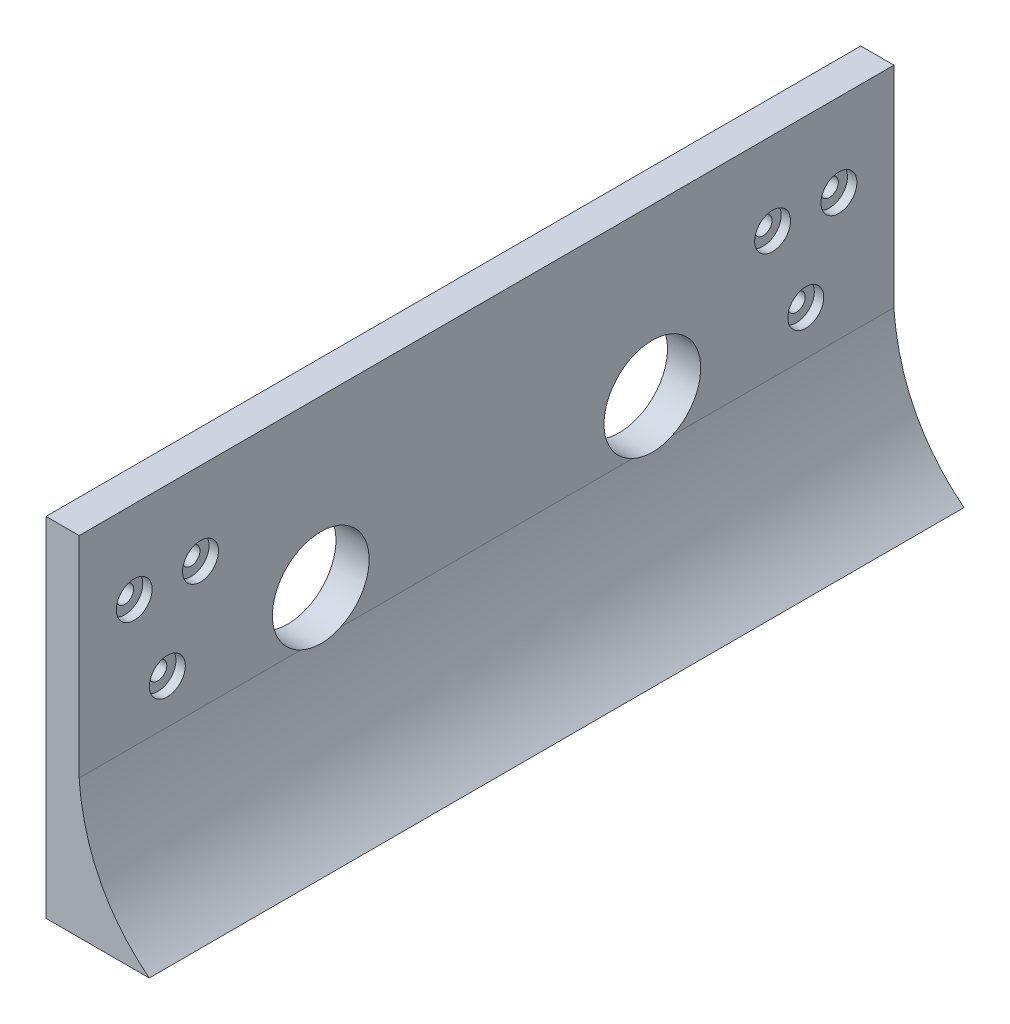
from build123d import *

# Parameters (mm, degrees)
SALIENTE_EXTRUIR1_DEPTH           = 73.717911
CORTAR_EXTRUIR1_REACH             = 8
CROQUIS3_R                        = 8.75
CORTAR_EXTRUIR1_DIRECTION_2_DEPTH = 0.4
CORTAR_EXTRUIR2_REACH             = 8
CROQUIS4_R                        = 1.6
CORTAR_EXTRUIR2_DIRECTION_2_DEPTH = 0.4
CROQUIS5_R                        = 3.25
CORTAR_EXTRUIR3_DEPTH             = 2.5


with BuildPart() as part:
    # Croquis1 → Saliente-Extruir1 (new body)
    with BuildSketch(Plane.XY):
        with BuildLine():
            Line((86.324875029, 72), (86.324875029, 9))
            Line((86.324875029, 9), (105, 9))
            add(Edge.make_bspline(
                [(105, 9), (93.439731725, 18.227197661), (92.324875029, 34)],
                knots=[0, 0, 0, 1, 1, 1], degree=2))
            Line((92.324875029, 34), (92.324875029, 72))
            Line((92.324875029, 72), (86.324875029, 72))
        make_face()
    saliente_extruir1 = extrude(amount=-SALIENTE_EXTRUIR1_DEPTH)

    # Simetr_a1: Saliente-Extruir1 across Front Plane
    add(saliente_extruir1.mirror(Plane.XY))

    # Croquis3 → Cortar-Extruir1 (cut, up to next)
    with BuildSketch(Plane(origin=(92.324875029, 0, 0), x_dir=(0, 0, -1), z_dir=(1, 0, 0)), mode=Mode.PRIVATE) as cortar_extruir1_sk1:
        with BuildLine():
            Line((33.54436172, 34), (26.45563828, 34))
            ThreePointArc((26.45563828, 34), (30, 33.25), (33.54436172, 34))
        make_face()
    cortar_extruir1_tool1 = extrude(cortar_extruir1_sk1.sketch, amount=-CORTAR_EXTRUIR1_REACH, mode=Mode.PRIVATE) & part.part
    add(cortar_extruir1_tool1.solids().sort_by_distance((92.324875, 33.69887, -30))[0], mode=Mode.SUBTRACT)
    # Croquis3 → Cortar-Extruir1 (cut, up to next)
    with BuildSketch(Plane(origin=(92.324875029, 0, 0), x_dir=(0, 0, -1), z_dir=(1, 0, 0)), mode=Mode.PRIVATE) as cortar_extruir1_sk2:
        with BuildLine():
            ThreePointArc((38.75, 42), (25.227718839, 49.334018852), (26.45563828, 34))
            Line((26.45563828, 34), (33.54436172, 34))
            ThreePointArc((33.54436172, 34), (37.334018852, 37.227718839), (38.75, 42))
        make_face()
    cortar_extruir1_tool2 = extrude(cortar_extruir1_sk2.sketch, amount=-CORTAR_EXTRUIR1_REACH, mode=Mode.PRIVATE) & part.part
    add(cortar_extruir1_tool2.solids().sort_by_distance((92.324875, 42.125274, -30))[0], mode=Mode.SUBTRACT)
    # Croquis3 → Cortar-Extruir1 (cut, up to next)
    with BuildSketch(Plane(origin=(92.324875029, 0, 0), x_dir=(0, 0, -1), z_dir=(1, 0, 0)), mode=Mode.PRIVATE) as cortar_extruir1_sk3:
        with Locations((-30, 42)):
            Circle(CROQUIS3_R)
    cortar_extruir1_tool3 = extrude(cortar_extruir1_sk3.sketch, amount=-CORTAR_EXTRUIR1_REACH, mode=Mode.PRIVATE) & part.part
    add(cortar_extruir1_tool3.solids().sort_by_distance((92.324875, 42, 30))[0], mode=Mode.SUBTRACT)

    # Croquis3 → Cortar-Extruir1 direction 2 (cut)
    with BuildSketch(Plane(origin=(92.324875029, 0, 0), x_dir=(0, 0, -1), z_dir=(1, 0, 0))):
        with BuildLine():
            Line((33.54436172, 34), (26.45563828, 34))
            ThreePointArc((26.45563828, 34), (30, 33.25), (33.54436172, 34))
        make_face()
        with BuildLine():
            ThreePointArc((38.75, 42), (25.227718839, 49.334018852), (26.45563828, 34))
            Line((26.45563828, 34), (33.54436172, 34))
            ThreePointArc((33.54436172, 34), (37.334018852, 37.227718839), (38.75, 42))
        make_face()
        with Locations((-30, 42)):
            Circle(CROQUIS3_R)
    extrude(amount=CORTAR_EXTRUIR1_DIRECTION_2_DEPTH, mode=Mode.SUBTRACT)

    # Croquis4 → Cortar-Extruir2 (cut, up to next)
    with BuildSketch(Plane(origin=(92.324875029, 0, 0), x_dir=(0, 0, -1), z_dir=(1, 0, 0)), mode=Mode.PRIVATE) as cortar_extruir2_sk1:
        with Locations((-57.761533754, 42)):
            Circle(CROQUIS4_R)
    cortar_extruir2_tool1 = extrude(cortar_extruir2_sk1.sketch, amount=-CORTAR_EXTRUIR2_REACH, mode=Mode.PRIVATE) & part.part
    add(cortar_extruir2_tool1.solids().sort_by_distance((92.324875, 42, 57.761534))[0], mode=Mode.SUBTRACT)
    # Croquis4 → Cortar-Extruir2 (cut, up to next)
    with BuildSketch(Plane(origin=(92.324875029, 0, 0), x_dir=(0, 0, -1), z_dir=(1, 0, 0)), mode=Mode.PRIVATE) as cortar_extruir2_sk2:
        with Locations((-63.761533754, 57)):
            Circle(CROQUIS4_R)
    cortar_extruir2_tool2 = extrude(cortar_extruir2_sk2.sketch, amount=-CORTAR_EXTRUIR2_REACH, mode=Mode.PRIVATE) & part.part
    add(cortar_extruir2_tool2.solids().sort_by_distance((92.324875, 57, 63.761534))[0], mode=Mode.SUBTRACT)
    # Croquis4 → Cortar-Extruir2 (cut, up to next)
    with BuildSketch(Plane(origin=(92.324875029, 0, 0), x_dir=(0, 0, -1), z_dir=(1, 0, 0)), mode=Mode.PRIVATE) as cortar_extruir2_sk3:
        with Locations((-51.761533754, 57)):
            Circle(CROQUIS4_R)
    cortar_extruir2_tool3 = extrude(cortar_extruir2_sk3.sketch, amount=-CORTAR_EXTRUIR2_REACH, mode=Mode.PRIVATE) & part.part
    add(cortar_extruir2_tool3.solids().sort_by_distance((92.324875, 57, 51.761534))[0], mode=Mode.SUBTRACT)
    # Croquis4 → Cortar-Extruir2 (cut, up to next)
    with BuildSketch(Plane(origin=(92.324875029, 0, 0), x_dir=(0, 0, -1), z_dir=(1, 0, 0)), mode=Mode.PRIVATE) as cortar_extruir2_sk4:
        with Locations((51.761533754, 57)):
            Circle(CROQUIS4_R)
    cortar_extruir2_tool4 = extrude(cortar_extruir2_sk4.sketch, amount=-CORTAR_EXTRUIR2_REACH, mode=Mode.PRIVATE) & part.part
    add(cortar_extruir2_tool4.solids().sort_by_distance((92.324875, 57, -51.761534))[0], mode=Mode.SUBTRACT)
    # Croquis4 → Cortar-Extruir2 (cut, up to next)
    with BuildSketch(Plane(origin=(92.324875029, 0, 0), x_dir=(0, 0, -1), z_dir=(1, 0, 0)), mode=Mode.PRIVATE) as cortar_extruir2_sk5:
        with Locations((63.761533754, 57)):
            Circle(CROQUIS4_R)
    cortar_extruir2_tool5 = extrude(cortar_extruir2_sk5.sketch, amount=-CORTAR_EXTRUIR2_REACH, mode=Mode.PRIVATE) & part.part
    add(cortar_extruir2_tool5.solids().sort_by_distance((92.324875, 57, -63.761534))[0], mode=Mode.SUBTRACT)
    # Croquis4 → Cortar-Extruir2 (cut, up to next)
    with BuildSketch(Plane(origin=(92.324875029, 0, 0), x_dir=(0, 0, -1), z_dir=(1, 0, 0)), mode=Mode.PRIVATE) as cortar_extruir2_sk6:
        with Locations((57.761533754, 42)):
            Circle(CROQUIS4_R)
    cortar_extruir2_tool6 = extrude(cortar_extruir2_sk6.sketch, amount=-CORTAR_EXTRUIR2_REACH, mode=Mode.PRIVATE) & part.part
    add(cortar_extruir2_tool6.solids().sort_by_distance((92.324875, 42, -57.761534))[0], mode=Mode.SUBTRACT)

    # Croquis4 → Cortar-Extruir2 direction 2 (cut)
    with BuildSketch(Plane(origin=(92.324875029, 0, 0), x_dir=(0, 0, -1), z_dir=(1, 0, 0))):
        with Locations((-57.761533754, 42)):
            Circle(CROQUIS4_R)
        with Locations((-63.761533754, 57)):
            Circle(CROQUIS4_R)
        with Locations((-51.761533754, 57)):
            Circle(CROQUIS4_R)
        with Locations((51.761533754, 57)):
            Circle(CROQUIS4_R)
        with Locations((63.761533754, 57)):
            Circle(CROQUIS4_R)
        with Locations((57.761533754, 42)):
            Circle(CROQUIS4_R)
    extrude(amount=CORTAR_EXTRUIR2_DIRECTION_2_DEPTH, mode=Mode.SUBTRACT)

    # Croquis5 → Cortar-Extruir3 (cut)
    with BuildSketch(Plane(origin=(93.124875029, 0, 0), x_dir=(0, 0, -1), z_dir=(1, 0, 0))):
        with Locations((-57.761533754, 42)):
            Circle(CROQUIS5_R)
        with Locations((-63.761533754, 57)):
            Circle(CROQUIS5_R)
        with Locations((-51.761533754, 57)):
            Circle(CROQUIS5_R)
        with Locations((51.761533754, 57)):
            Circle(CROQUIS5_R)
        with Locations((63.761533754, 57)):
            Circle(CROQUIS5_R)
        with Locations((57.761533754, 42)):
            Circle(CROQUIS5_R)
    extrude(amount=-CORTAR_EXTRUIR3_DEPTH, mode=Mode.SUBTRACT)


solid = part.part
